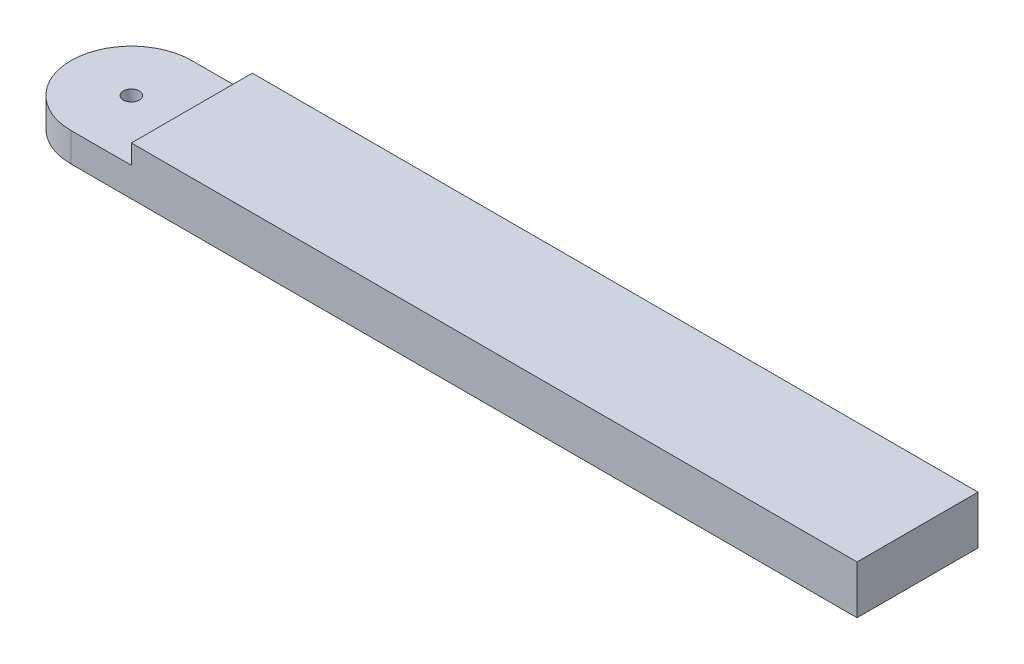
from build123d import *

# Parameters (mm, degrees)
SKETCH1_R           = 1.65
BOSS_EXTRUDE1_DEPTH = 10
SKETCH2_W           = 29.50673097
SKETCH2_H           = 30.126833799
CUT_EXTRUDE1_DEPTH  = 4


with BuildPart() as part:
    # Sketch1 → Boss-Extrude1 (new body)
    with BuildSketch(Plane(origin=(0, 0, 0), x_dir=(1, 0, 0), z_dir=(0, 1, 0))):
        with BuildLine():
            Line((-41.547817516, 10.435693018), (120.952182484, 10.435693018))
            Line((120.952182484, 10.435693018), (120.952182484, -14.564306982))
            Line((120.952182484, -14.564306982), (-41.547817516, -14.564306982))
            ThreePointArc((-41.547817516, -14.564306982), (-54.047817516, -2.064306982), (-41.547817516, 10.435693018))
        make_face()
        with Locations((-41.547817516, -2.064306982)):
            Circle(SKETCH1_R, mode=Mode.SUBTRACT)
    extrude(amount=BOSS_EXTRUDE1_DEPTH)

    # Sketch2 → Cut-Extrude1 (cut)
    with BuildSketch(Plane(origin=(0, 10, 0), x_dir=(1, 0, 0), z_dir=(0, 1, 0))):
        with Locations((-43.801183001, 0.499109917)):
            Rectangle(SKETCH2_W, SKETCH2_H)
    extrude(amount=-CUT_EXTRUDE1_DEPTH, mode=Mode.SUBTRACT)


solid = part.part
